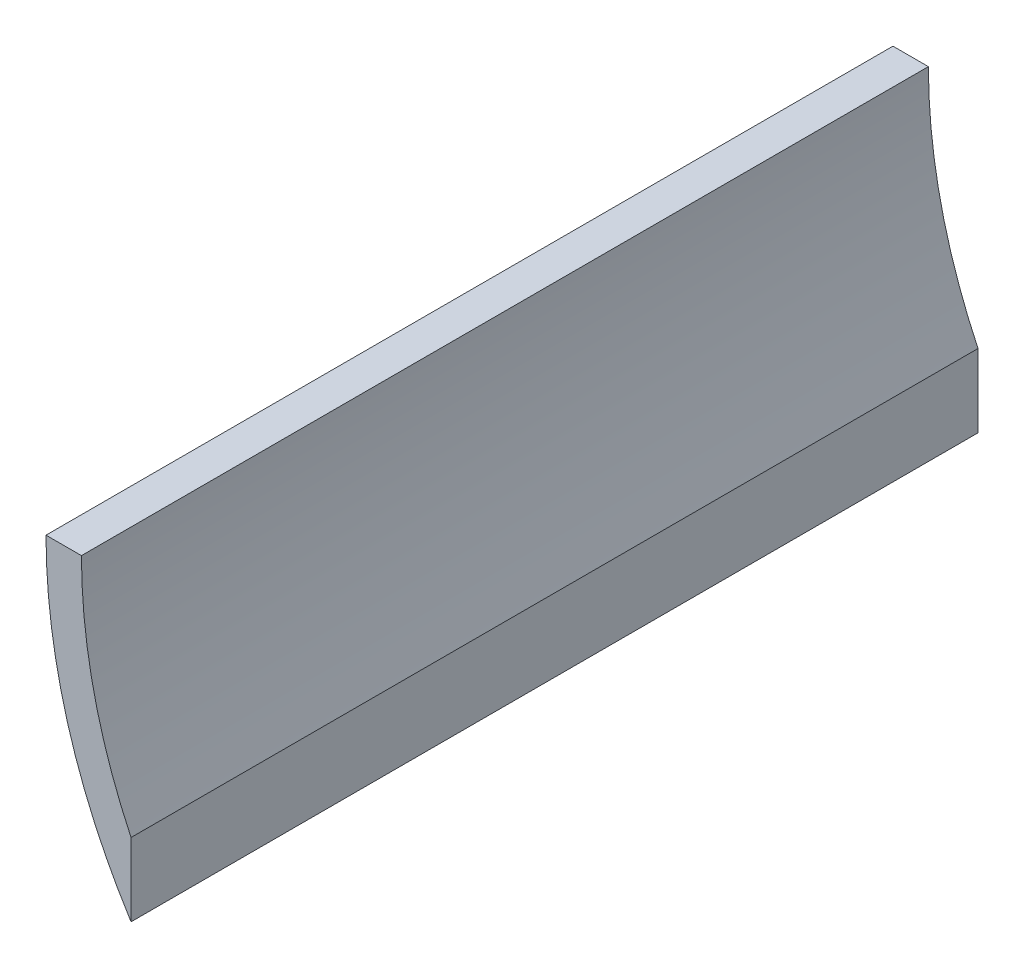
from build123d import *

# Parameters (mm, degrees)
BOSS_EXTRUDE1_DEPTH = 239


with BuildPart() as part:
    # Sketch1 → Boss-Extrude1 (new body)
    with BuildSketch(Plane.XY):
        with BuildLine():
            Line((-82, -47.176082117), (-82, -67.786563618))
            ThreePointArc((-82, -67.786563618), (-99.878161008, -28.246574093), (-106, 14.713436382))
            Line((-106, 14.713436382), (-96, 14.713436382))
            ThreePointArc((-96, 14.713436382), (-92.456335782, -17.013179022), (-82, -47.176082117))
        make_face()
    extrude(amount=BOSS_EXTRUDE1_DEPTH)


solid = part.part
